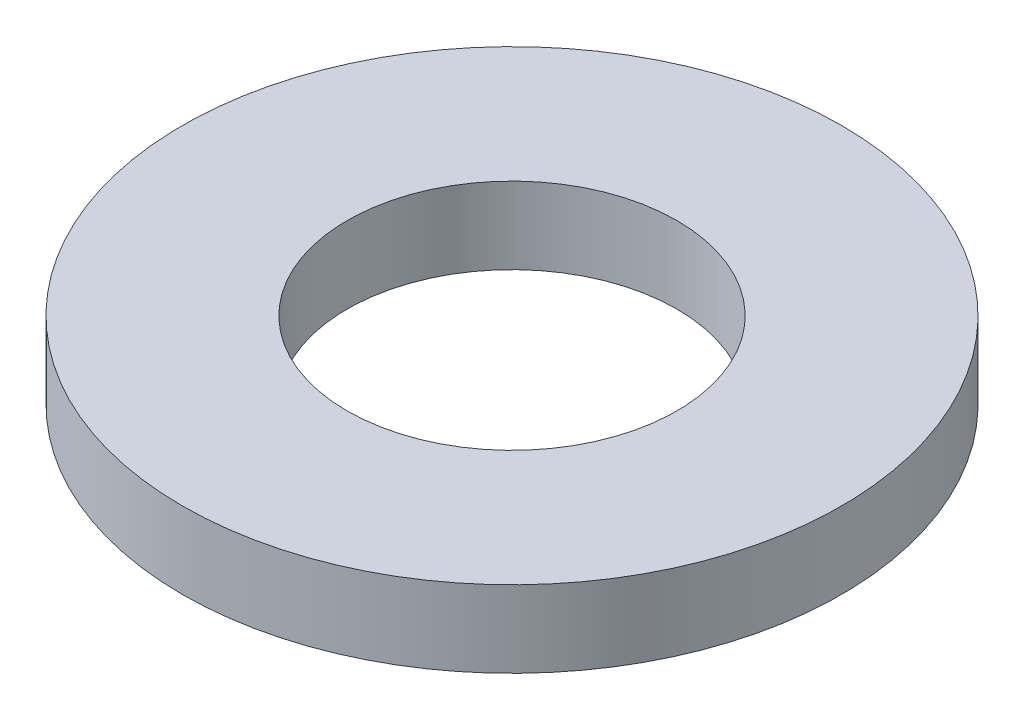
from build123d import *

# Parameters (mm, degrees)
SKETCH1_R           = 8.73125
BOSS_EXTRUDE1_DEPTH = 2.032
SKETCH5_R           = 4.3688
CUT_EXTRUDE1_DEPTH  = 3.032


with BuildPart() as part:
    # Sketch1 → Boss-Extrude1 (new body)
    with BuildSketch(Plane(origin=(0, 0, 0), x_dir=(1, 0, 0), z_dir=(0, 1, 0))):
        Circle(SKETCH1_R)
    extrude(amount=BOSS_EXTRUDE1_DEPTH)

    # Sketch5 → Cut-Extrude1 (cut, through all)
    with BuildSketch(Plane(origin=(0, 2.032, 0), x_dir=(-1, 0, 0), z_dir=(0, 1, 0))):
        Circle(SKETCH5_R)
    extrude(amount=-CUT_EXTRUDE1_DEPTH, mode=Mode.SUBTRACT)


solid = part.part
